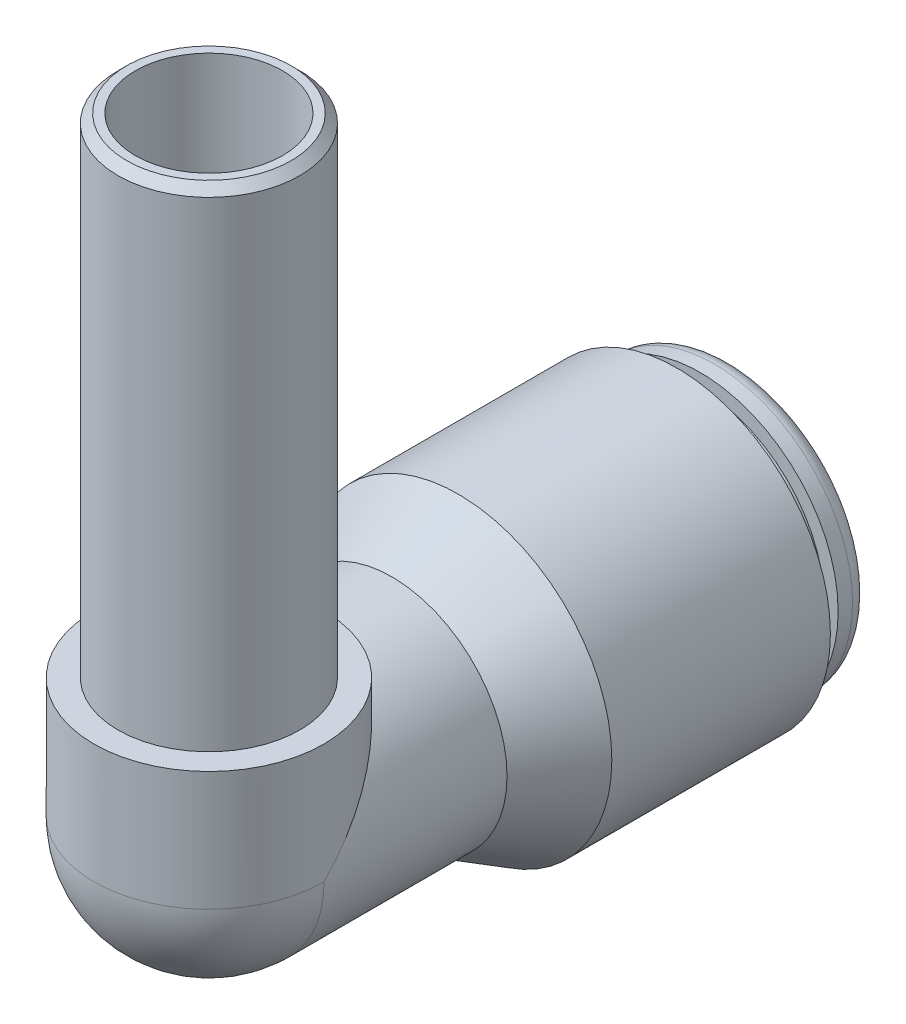
from build123d import *
from build123d.topology import SkipClean

# Parameters (mm, degrees)
SKETCH9_R          = 4
SKETCH9_R_2        = 3.238
EXTRUDE1_DEPTH     = 5.0625
REVOLVE2_ANGLE     = 90
EXTRUDE2_DEPTH     = 5.25
EXTRUDE5_START     = -5.25
SKETCH16_R         = 5.0625
SKETCH16_R_2       = 3.238
EXTRUDE5_DEPTH     = 5.25
SKETCH12_R         = 3.238
CUT_EXTRUDE1_DEPTH = 25.90230913
CUT_EXTRUDE2_START = 5.0625
SKETCH13_R         = 3.238
CUT_EXTRUDE2_DEPTH = 5.0625
SKETCH15_R         = 4
SKETCH15_R_2       = 3.238
EXTRUDE4_DEPTH     = 21.5
CHAMFER1_SIZE      = 0.381


with BuildPart() as part:
    # Sketch8 → Revolve1 (revolve)
    with BuildSketch(Plane(origin=(0, 0, 0), x_dir=(0, 0, -1), z_dir=(1, 0, 0)), mode=Mode.PRIVATE) as revolve1_sk:
        with BuildLine():
            Line((21.603, 6.075), (22.238, 6.075))
            ThreePointArc((22.238, 6.075), (22.776815367, 5.851815367), (23, 5.313))
            Line((23, 5.313), (23, 4.381))
            Line((23, 4.381), (22.619, 4))
            Line((22.619, 4), (0, 4))
            Line((0, 4), (0, 5.0625))
            Line((0, 5.0625), (8.05, 5.0625))
            Line((8.05, 5.0625), (10.972835738, 6.75))
            Line((10.972835738, 6.75), (20.587, 6.75))
            Line((20.587, 6.75), (20.587, 5.4675))
            Line((20.587, 5.4675), (21.603, 5.4675))
            Line((21.603, 5.4675), (21.603, 6.075))
        make_face()
    revolve(revolve1_sk.sketch.rotate(Axis((0, 0, 0), (0, 0, -1)), 90), axis=Axis((0, 0, 0), (0, 0, -1)))

    # Sketch9 → Extrude1 (add)
    with BuildSketch(Plane.XY):
        Circle(SKETCH9_R)
        Circle(SKETCH9_R_2, mode=Mode.SUBTRACT)
    extrude(amount=-EXTRUDE1_DEPTH)

    # Sketch11 → Revolve2 (revolve)
    with BuildSketch(Plane.XY):
        with BuildLine():
            Line((-5.0625, 0), (-3.238, 0))
            ThreePointArc((-3.238, 0), (0, -3.238), (3.238, 0))
            Line((3.238, 0), (5.0625, 0))
            ThreePointArc((5.0625, 0), (0, -5.0625), (-5.0625, 0))
        make_face()
    revolve(axis=Axis((-5.0625, 0, 0), (-1, 0, 0)), revolution_arc=REVOLVE2_ANGLE)

    # Sketch14 → Extrude2 (add)
    with BuildSketch(Plane(origin=(0, 0, 0), x_dir=(-1, 0, 0), z_dir=(0, 1, 0))):
        with BuildLine():
            Line((-5.0625, 0), (-3.238, 0))
            ThreePointArc((-3.238, 0), (0, 3.238), (3.238, 0))
            Line((3.238, 0), (5.0625, 0))
            ThreePointArc((5.0625, 0), (0, 5.0625), (-5.0625, 0))
        make_face()
    extrude(amount=EXTRUDE2_DEPTH)

    # Sketch16 → Extrude5 (add)
    with SkipClean():  # the faces are left unmerged after this step: merging them gives an invalid solid
        with BuildSketch(Plane(origin=(0, 5.25, 0), x_dir=(-1, 0, 0), z_dir=(0, 1, 0)).offset(EXTRUDE5_START)):
            with Locations(Location((0, 0, 0), (0, 0, 180))):
                Circle(SKETCH16_R)
            with Locations(Location((0, 0, 0), (0, 0, 180))):
                Circle(SKETCH16_R_2, mode=Mode.SUBTRACT)
        extrude(amount=EXTRUDE5_DEPTH)

    # Sketch12 → Cut-Extrude1 (cut, through all)
    with BuildSketch(Plane(origin=(0, 0, 0), x_dir=(1, 0, 0), z_dir=(0, 1, 0))):
        Circle(SKETCH12_R)
    extrude(amount=CUT_EXTRUDE1_DEPTH, mode=Mode.SUBTRACT)

    # Sketch13 → Cut-Extrude2 (cut)
    with BuildSketch(Plane.XY.offset(-5.0625).offset(CUT_EXTRUDE2_START)):
        Circle(SKETCH13_R)
    extrude(amount=-CUT_EXTRUDE2_DEPTH, mode=Mode.SUBTRACT)

    # Sketch15 → Extrude4 (add)
    with BuildSketch(Plane(origin=(0, 5.25, 0), x_dir=(-1, 0, 0), z_dir=(0, 1, 0))):
        with Locations(Location((0, 0, 0), (0, 0, 90))):
            Circle(SKETCH15_R)
        with Locations(Location((0, 0, 0), (0, 0, 180))):
            Circle(SKETCH15_R_2, mode=Mode.SUBTRACT)
    extrude(amount=EXTRUDE4_DEPTH)

    # Chamfer1
    chamfer1_edges = [part.edges().sort_by_distance(p)[0] for p in [
        (0, 26.75, -4),
    ]]
    chamfer(chamfer1_edges, length=CHAMFER1_SIZE)


solid = part.part
